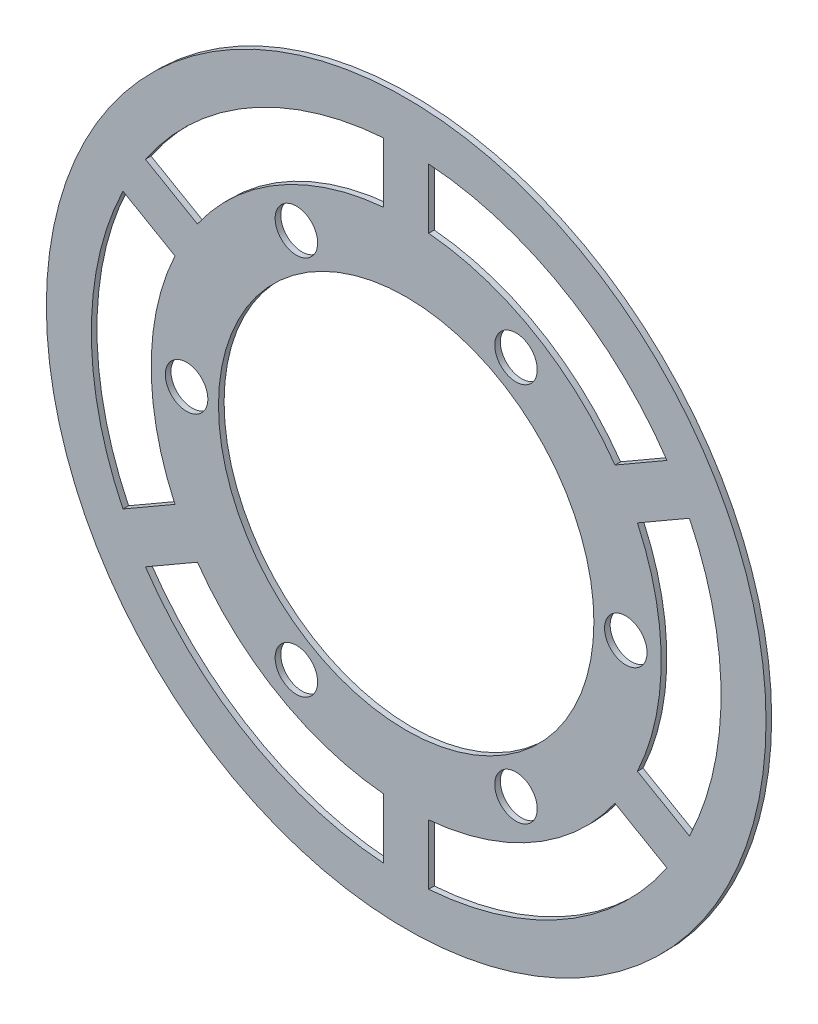
from build123d import *

# Parameters (mm, degrees)
SKETCH1_R           = 25.4
SKETCH1_R_2         = 1.5
SKETCH1_R_3         = 13.25
BOSS_EXTRUDE1_DEPTH = 0.396875


with BuildPart() as part:
    # Sketch1 → Boss-Extrude1 (new body)
    with BuildSketch(Plane.XY):
        Circle(SKETCH1_R)
        with Locations((-15.5, 0)):
            Circle(SKETCH1_R_2, mode=Mode.SUBTRACT)
        with Locations((-7.75, 13.423393759)):
            Circle(SKETCH1_R_2, mode=Mode.SUBTRACT)
        with Locations((7.75, 13.423393759)):
            Circle(SKETCH1_R_2, mode=Mode.SUBTRACT)
        with Locations((15.5, 0)):
            Circle(SKETCH1_R_2, mode=Mode.SUBTRACT)
        with Locations((7.75, -13.423393759)):
            Circle(SKETCH1_R_2, mode=Mode.SUBTRACT)
        with Locations((-7.75, -13.423393759)):
            Circle(SKETCH1_R_2, mode=Mode.SUBTRACT)
        Circle(SKETCH1_R_3, mode=Mode.SUBTRACT)
        with BuildLine():
            Line((-1.584648919, 17.930111204), (-1.584648919, 22.168435055))
            ThreePointArc((-1.584648919, 22.168435055), (-11.1125, 19.247414599), (-18.406103461, 12.456563747))
            Line((-18.406103461, 12.456563747), (-14.735607336, 10.337401822))
            ThreePointArc((-14.735607336, 10.337401822), (-9, 15.588457268), (-1.584648919, 17.930111204))
        make_face(mode=Mode.SUBTRACT)
        with BuildLine():
            Line((1.584648919, 17.930111204), (1.584648919, 22.168435055))
            ThreePointArc((1.584648919, 22.168435055), (11.1125, 19.247414599), (18.406103461, 12.456563747))
            Line((18.406103461, 12.456563747), (14.735607336, 10.337401822))
            ThreePointArc((14.735607336, 10.337401822), (9, 15.588457268), (1.584648919, 17.930111204))
        make_face(mode=Mode.SUBTRACT)
        with BuildLine():
            Line((16.320256255, 7.592709383), (19.990752379, 9.711871308))
            ThreePointArc((19.990752379, 9.711871308), (22.225, 0), (19.990752379, -9.711871308))
            Line((19.990752379, -9.711871308), (16.320256255, -7.592709383))
            ThreePointArc((16.320256255, -7.592709383), (18, 0), (16.320256255, 7.592709383))
        make_face(mode=Mode.SUBTRACT)
        with BuildLine():
            Line((-16.320256255, 7.592709383), (-19.990752379, 9.711871308))
            ThreePointArc((-19.990752379, 9.711871308), (-22.225, 0), (-19.990752379, -9.711871308))
            Line((-19.990752379, -9.711871308), (-16.320256255, -7.592709383))
            ThreePointArc((-16.320256255, -7.592709383), (-18, 0), (-16.320256255, 7.592709383))
        make_face(mode=Mode.SUBTRACT)
        with BuildLine():
            Line((-14.735607336, -10.337401822), (-18.406103461, -12.456563747))
            ThreePointArc((-18.406103461, -12.456563747), (-11.1125, -19.247414599), (-1.584648919, -22.168435055))
            Line((-1.584648919, -22.168435055), (-1.584648919, -17.930111204))
            ThreePointArc((-1.584648919, -17.930111204), (-9, -15.588457268), (-14.735607336, -10.337401822))
        make_face(mode=Mode.SUBTRACT)
        with BuildLine():
            Line((1.584648919, -17.930111204), (1.584648919, -22.168435055))
            ThreePointArc((1.584648919, -22.168435055), (11.1125, -19.247414599), (18.406103461, -12.456563747))
            Line((18.406103461, -12.456563747), (14.735607336, -10.337401822))
            ThreePointArc((14.735607336, -10.337401822), (9, -15.588457268), (1.584648919, -17.930111204))
        make_face(mode=Mode.SUBTRACT)
    extrude(amount=BOSS_EXTRUDE1_DEPTH)


solid = part.part
